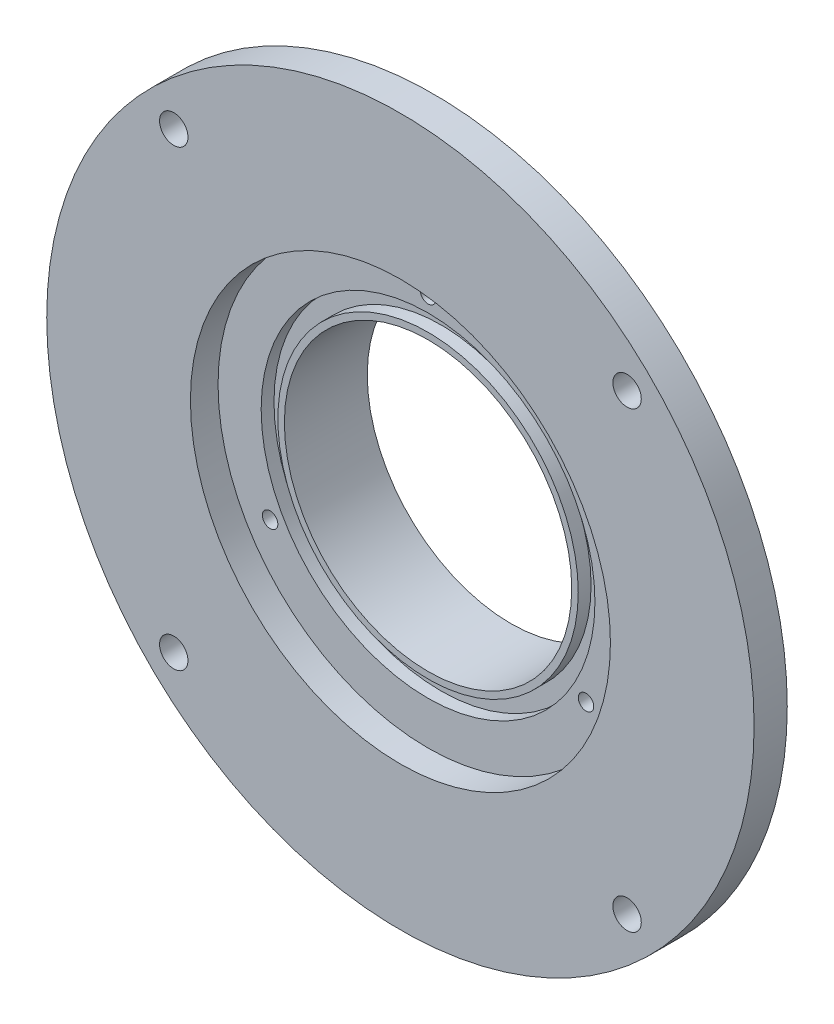
from build123d import *

# Parameters (mm, degrees)
SKETCH1_R             = 40.64
EXTRUDE1_DEPTH        = 3.81
F_4_CLEARANCE_HOLE1_D = 3.2639
SKETCH6_R             = 27.94
EXTRUDE2_DEPTH        = 8.89
SKETCH5_R             = 16.51
CUT_EXTRUDE2_DEPTH    = 13.7
SKETCH14_R            = 24.13
CUT_EXTRUDE3_DEPTH    = 3.175
CIRPATTERN1_COUNT     = 3
SKETCH13_R            = 19.177
SKETCH13_R_2          = 17.2593
CUT_EXTRUDE4_DEPTH    = 1.4732


with BuildPart() as part:
    # Sketch1 → Extrude1 (new body)
    with BuildSketch(Plane.XY):
        Circle(SKETCH1_R)
    extrude(amount=EXTRUDE1_DEPTH)

    # #4 Clearance Hole1 (through all)
    with Locations(Plane.XY.offset(3.81)):
        with Locations((26.042742751, 26.042742751), (26.042742751, -26.042742751), (-26.042288216, 26.043197279), (-26.04251548, -26.04297002)):
            Hole(F_4_CLEARANCE_HOLE1_D / 2)

    # Sketch6 → Extrude2 (add)
    with BuildSketch(Plane(origin=(0, 0, 0), x_dir=(-1, 0, 0), z_dir=(0, 0, -1))):
        Circle(SKETCH6_R)
    extrude(amount=EXTRUDE2_DEPTH)

    # Sketch5 → Cut-Extrude2 (cut, through all)
    with BuildSketch(Plane.XY.offset(3.81)):
        Circle(SKETCH5_R)
    extrude(amount=-CUT_EXTRUDE2_DEPTH, mode=Mode.SUBTRACT)

    # Sketch14 → Cut-Extrude3 (cut)
    with BuildSketch(Plane.XY.offset(3.81)):
        Circle(SKETCH14_R)
    extrude(amount=-CUT_EXTRUDE3_DEPTH, mode=Mode.SUBTRACT)

    # Sketch16 → #2-56 Tapped Hole1 (revolve, cut)
    with BuildSketch(Plane(origin=(0, 20.955, 0.635), x_dir=(0, -1, 0), z_dir=(1, 0, 0))):
        Polygon((0, 0), (0, 4.95376509), (0.889, 4.4196), (0.889, 0), align=None)
    f_2_56_tapped_hole1 = revolve(axis=Axis((0, 20.955, 6.985), (0, 0, -1)), mode=Mode.SUBTRACT)

    # CirPattern1: #2-56 Tapped Hole1 ×3 about axis
    cirpattern1_axis = Axis((0, 0, 0), (0, 0, 1))
    for i in range(1, CIRPATTERN1_COUNT):
        add(f_2_56_tapped_hole1.rotate(cirpattern1_axis, i * 360 / CIRPATTERN1_COUNT), mode=Mode.SUBTRACT)

    # Sketch13 → Cut-Extrude4 (cut)
    with BuildSketch(Plane.XY.offset(0.635)):
        Circle(SKETCH13_R)
        Circle(SKETCH13_R_2, mode=Mode.SUBTRACT)
    extrude(amount=-CUT_EXTRUDE4_DEPTH, mode=Mode.SUBTRACT)


solid = part.part
